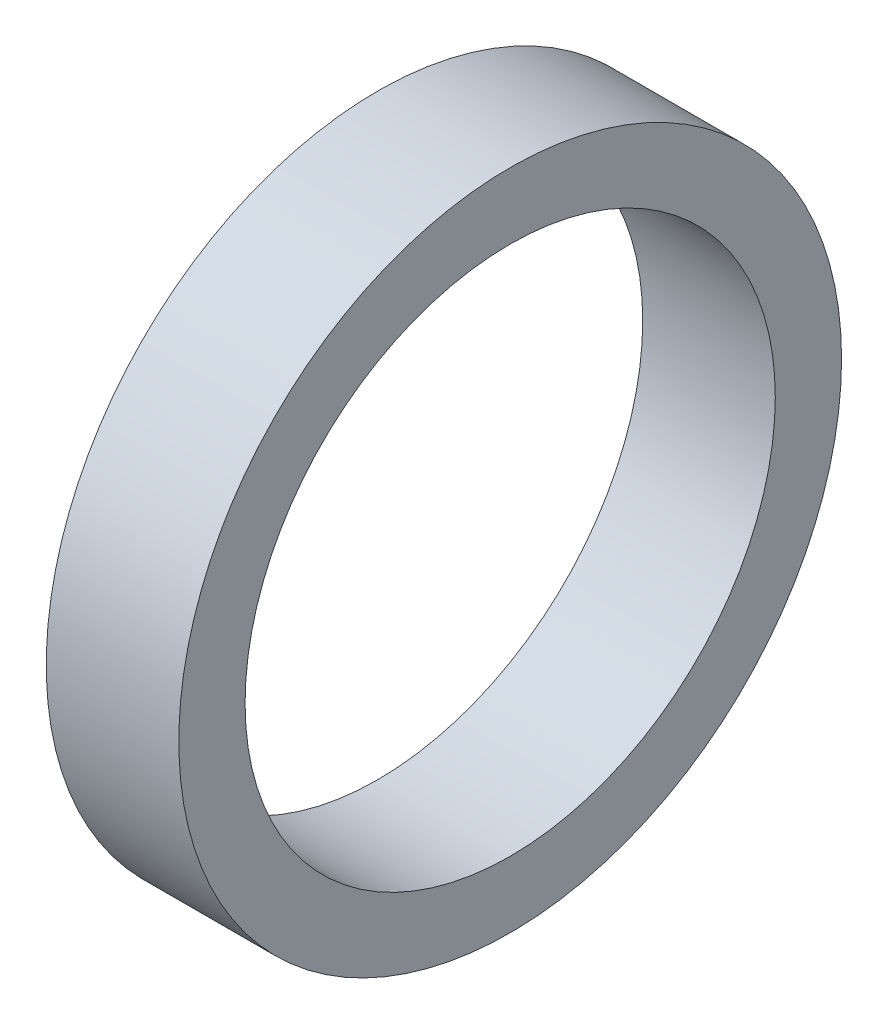
from build123d import *

# Parameters (mm, degrees)
SKETCH_3_R          = 2.5
EXTRUDE_2_DEPTH     = 1
SKETCH_4_R          = 2
CUT_EXTRUDE_1_DEPTH = 1


with BuildPart() as part:
    # Эскиз3 → Бобышка-Вытянуть2 (new body)
    with BuildSketch(Plane(origin=(0, 0, 0), x_dir=(0, 0, -1), z_dir=(1, 0, 0))):
        Circle(SKETCH_3_R)
    extrude(amount=EXTRUDE_2_DEPTH)

    # Эскиз4 → Вырез-Вытянуть1 (cut)
    with BuildSketch(Plane(origin=(1, 0, 0), x_dir=(0, 0, -1), z_dir=(1, 0, 0))):
        Circle(SKETCH_4_R)
    extrude(amount=-CUT_EXTRUDE_1_DEPTH, mode=Mode.SUBTRACT)


solid = part.part
